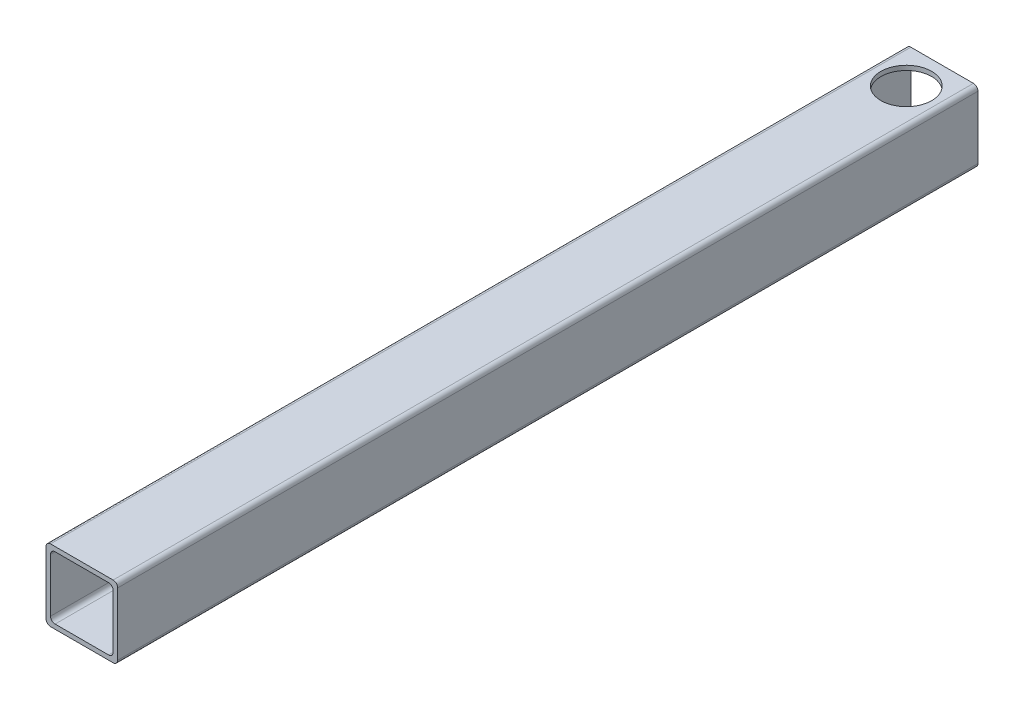
from build123d import *

# Parameters (mm, degrees)
BOSS_EXTRUDE1_DEPTH = 457.2
SKETCH2_R           = 13.49375
CUT_EXTRUDE1_DEPTH  = 228.6


with BuildPart() as part:
    # Sketch1 → Boss-Extrude1 (new body)
    with BuildSketch(Plane.XY):
        with BuildLine():
            Line((-16.637, -19.05), (16.637, -19.05))
            ThreePointArc((16.637, -19.05), (18.343248663, -18.343248663), (19.05, -16.637))
            Line((19.05, -16.637), (19.05, 16.637))
            ThreePointArc((19.05, 16.637), (18.343248663, 18.343248663), (16.637, 19.05))
            Line((16.637, 19.05), (-16.637, 19.05))
            ThreePointArc((-16.637, 19.05), (-18.343248663, 18.343248663), (-19.05, 16.637))
            Line((-19.05, 16.637), (-19.05, -16.637))
            ThreePointArc((-19.05, -16.637), (-18.343248663, -18.343248663), (-16.637, -19.05))
        make_face()
        with BuildLine():
            Line((-14.224, -16.637), (14.224, -16.637))
            ThreePointArc((14.224, -16.637), (15.930248663, -15.930248663), (16.637, -14.224))
            Line((16.637, -14.224), (16.637, 14.224))
            ThreePointArc((16.637, 14.224), (15.930248663, 15.930248663), (14.224, 16.637))
            Line((14.224, 16.637), (-14.224, 16.637))
            ThreePointArc((-14.224, 16.637), (-15.930248663, 15.930248663), (-16.637, 14.224))
            Line((-16.637, 14.224), (-16.637, -14.224))
            ThreePointArc((-16.637, -14.224), (-15.930248663, -15.930248663), (-14.224, -16.637))
        make_face(mode=Mode.SUBTRACT)
    extrude(amount=BOSS_EXTRUDE1_DEPTH)

    # Sketch2 → Cut-Extrude1 (cut, symmetric)
    with BuildSketch(Plane(origin=(0, 0, 0), x_dir=(1, 0, 0), z_dir=(0, 1, 0))):
        with Locations((0, -19.05)):
            Circle(SKETCH2_R)
    extrude(amount=CUT_EXTRUDE1_DEPTH, both=True, mode=Mode.SUBTRACT)


solid = part.part
